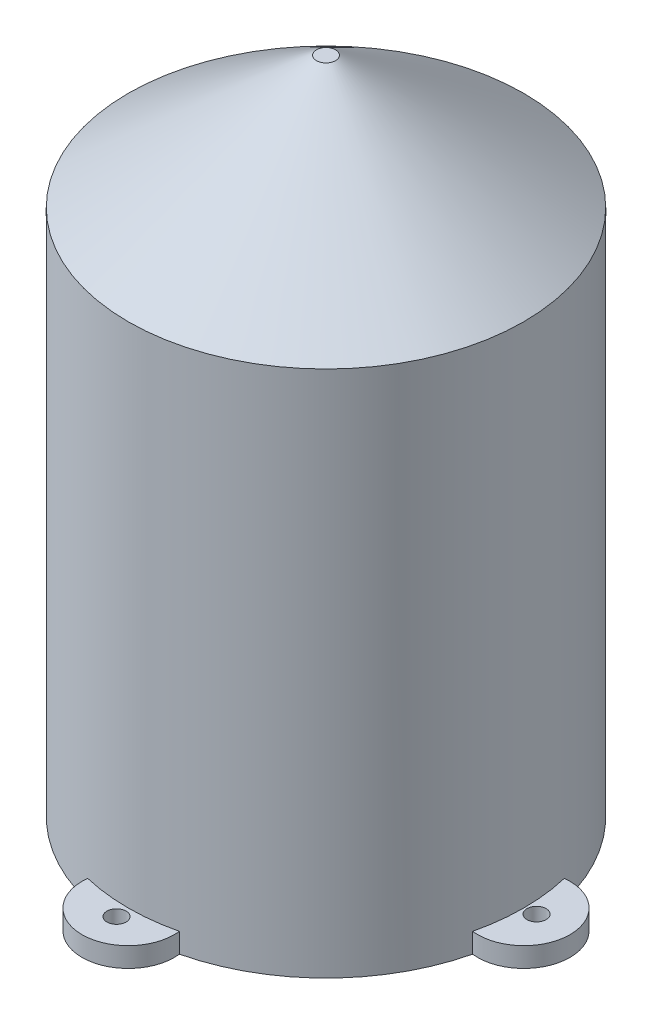
from build123d import *

# Parameters (mm, degrees)
SKETCH1_R                 = 30
BOSS_EXTRUDE1_DEPTH       = 100
CHAMFER1_SIZE             = 20
CHAMFER1_SIZE2            = 28.562960135
SHELL1_T                  = -2
BOSS_EXTRUDE2_DEPTH       = 3
F_1_0MM_DOWEL_HOLE1_D     = 2.9
F_1_0MM_DOWEL_HOLE1_DEPTH = 9.128752102
F_1_0MM_DOWEL_HOLE1_TIP   = 0.871247898


with BuildPart() as part:
    # Sketch1 → Boss-Extrude1 (new body)
    with BuildSketch(Plane(origin=(0, 0, 0), x_dir=(1, 0, 0), z_dir=(0, 1, 0))):
        with Locations(Location((0, 0, 0), (0, 0, 270))):
            Circle(SKETCH1_R)
    extrude(amount=BOSS_EXTRUDE1_DEPTH)

    # Chamfer1
    chamfer1_edges = [part.edges().sort_by_distance(p)[0] for p in [
        (0, 100, -30),
    ]]
    chamfer1_side = [part.faces().sort_by_distance(p)[0] for p in [
        (0, 50, -30),
    ]]
    chamfer(chamfer1_edges, length=CHAMFER1_SIZE, length2=CHAMFER1_SIZE2, reference=chamfer1_side[0])

    # Shell1
    shell1_openings = [part.faces().sort_by_distance(p)[0] for p in [
        (0, 0, 0),
    ]]
    offset(amount=SHELL1_T, openings=shell1_openings, kind=Kind.INTERSECTION)

    # Sketch2 → Boss-Extrude2 (add)
    with BuildSketch(Plane.XZ):
        with BuildLine():
            ThreePointArc((29.183333333, -6.952197894), (37, 0), (29.183333333, 6.952197894))
            ThreePointArc((29.183333333, 6.952197894), (29.795133831, 3.5), (30, 0))
            ThreePointArc((30, 0), (29.795133831, -3.5), (29.183333333, -6.952197894))
        make_face()
        with BuildLine():
            ThreePointArc((-6.952197894, 29.183333333), (0, 30), (6.952197894, 29.183333333))
            ThreePointArc((6.952197894, 29.183333333), (0, 37), (-6.952197894, 29.183333333))
        make_face()
        with BuildLine():
            ThreePointArc((-29.183333333, -6.952197894), (-30, 0), (-29.183333333, 6.952197894))
            ThreePointArc((-29.183333333, 6.952197894), (-37, 0), (-29.183333333, -6.952197894))
        make_face()
        with BuildLine():
            ThreePointArc((-6.952197894, -29.183333333), (0, -37), (6.952197894, -29.183333333))
            ThreePointArc((6.952197894, -29.183333333), (0, -30), (-6.952197894, -29.183333333))
        make_face()
    extrude(amount=-BOSS_EXTRUDE2_DEPTH)

    # Ø1.0mm Dowel Hole1
    with Locations(Plane(origin=(0.238867715, 0, 32.008273773), x_dir=(0, 0, -1), z_dir=(0, -1, 0))):
        with Locations((0, 0), (32.167518916, 31.530538344), (64.972018405, -0.47773543), (32.326764059, -32.963744633)):
            Hole(F_1_0MM_DOWEL_HOLE1_D / 2, depth=F_1_0MM_DOWEL_HOLE1_DEPTH)
            with Locations((0, 0, -(F_1_0MM_DOWEL_HOLE1_DEPTH + F_1_0MM_DOWEL_HOLE1_TIP / 2))):  # 118° drill point
                Cone(0, F_1_0MM_DOWEL_HOLE1_D / 2, F_1_0MM_DOWEL_HOLE1_TIP, mode=Mode.SUBTRACT)


solid = part.part
